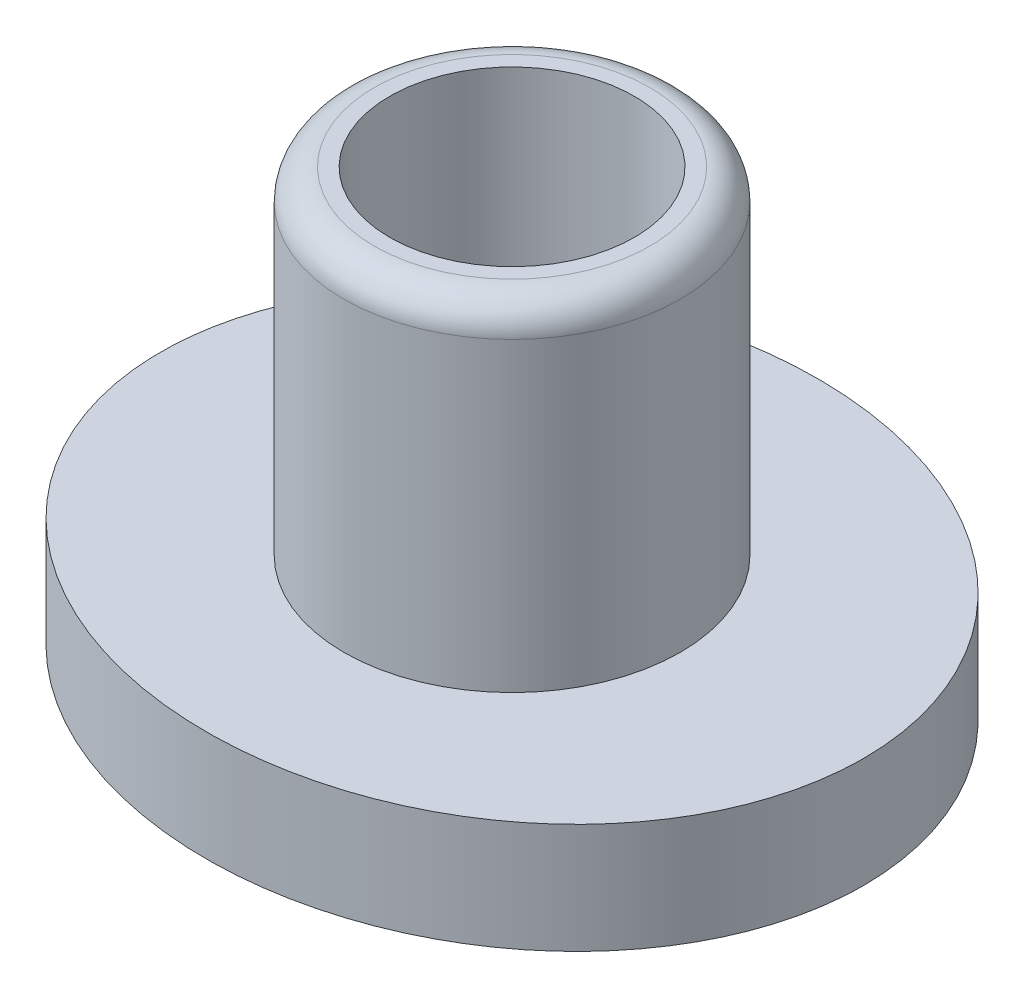
from build123d import *

# Parameters (mm, degrees)
SKETCH1_RX          = 5.75
SKETCH1_RY          = 5
BOSS_EXTRUDE1_DEPTH = 1.8
SKETCH2_R           = 2.75
BOSS_EXTRUDE2_DEPTH = 5.5
SKETCH3_R           = 2
CUT_EXTRUDE1_DEPTH  = 8.3
FILLET1_R           = 0.25
FILLET2_R           = 0.5


with BuildPart() as part:
    # Sketch1 → Boss-Extrude1 (new body)
    with BuildSketch(Plane(origin=(0, 0, 0), x_dir=(1, 0, 0), z_dir=(0, 1, 0))):
        with Locations((0, 0)):
            Ellipse(SKETCH1_RX, SKETCH1_RY)
    extrude(amount=BOSS_EXTRUDE1_DEPTH)

    # Sketch2 → Boss-Extrude2 (add)
    with BuildSketch(Plane(origin=(0, 1.8, 0), x_dir=(1, 0, 0), z_dir=(0, 1, 0))):
        Circle(SKETCH2_R)
    extrude(amount=BOSS_EXTRUDE2_DEPTH)

    # Sketch3 → Cut-Extrude1 (cut, through all)
    with BuildSketch(Plane(origin=(0, 7.3, 0), x_dir=(1, 0, 0), z_dir=(0, 1, 0))):
        Circle(SKETCH3_R)
    extrude(amount=-CUT_EXTRUDE1_DEPTH, mode=Mode.SUBTRACT)

    # Fillet1
    fillet1_edges = [part.edges().sort_by_distance(p)[0] for p in [
        (-2, 0, 0),
    ]]
    fillet(fillet1_edges, radius=FILLET1_R)

    # Fillet2
    fillet2_edges = [part.edges().sort_by_distance(p)[0] for p in [
        (-2.75, 7.3, 0),
    ]]
    fillet(fillet2_edges, radius=FILLET2_R)


solid = part.part
